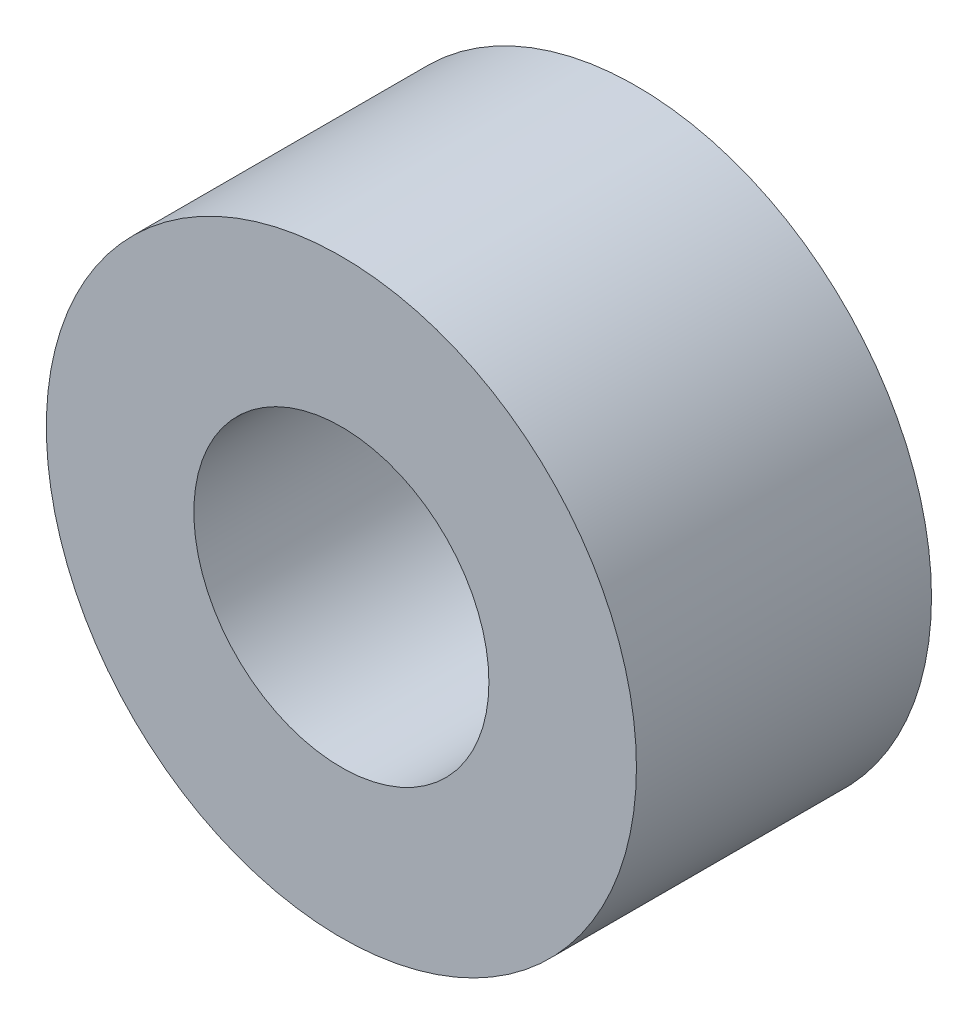
from build123d import *

# Parameters (mm, degrees)
SKETCH1_R           = 3
SKETCH1_R_2         = 1.5
BOSS_EXTRUDE1_DEPTH = 3


with BuildPart() as part:
    # Sketch1 → Boss-Extrude1 (new body)
    with BuildSketch(Plane.XY):
        Circle(SKETCH1_R)
        Circle(SKETCH1_R_2, mode=Mode.SUBTRACT)
    extrude(amount=BOSS_EXTRUDE1_DEPTH)


solid = part.part
